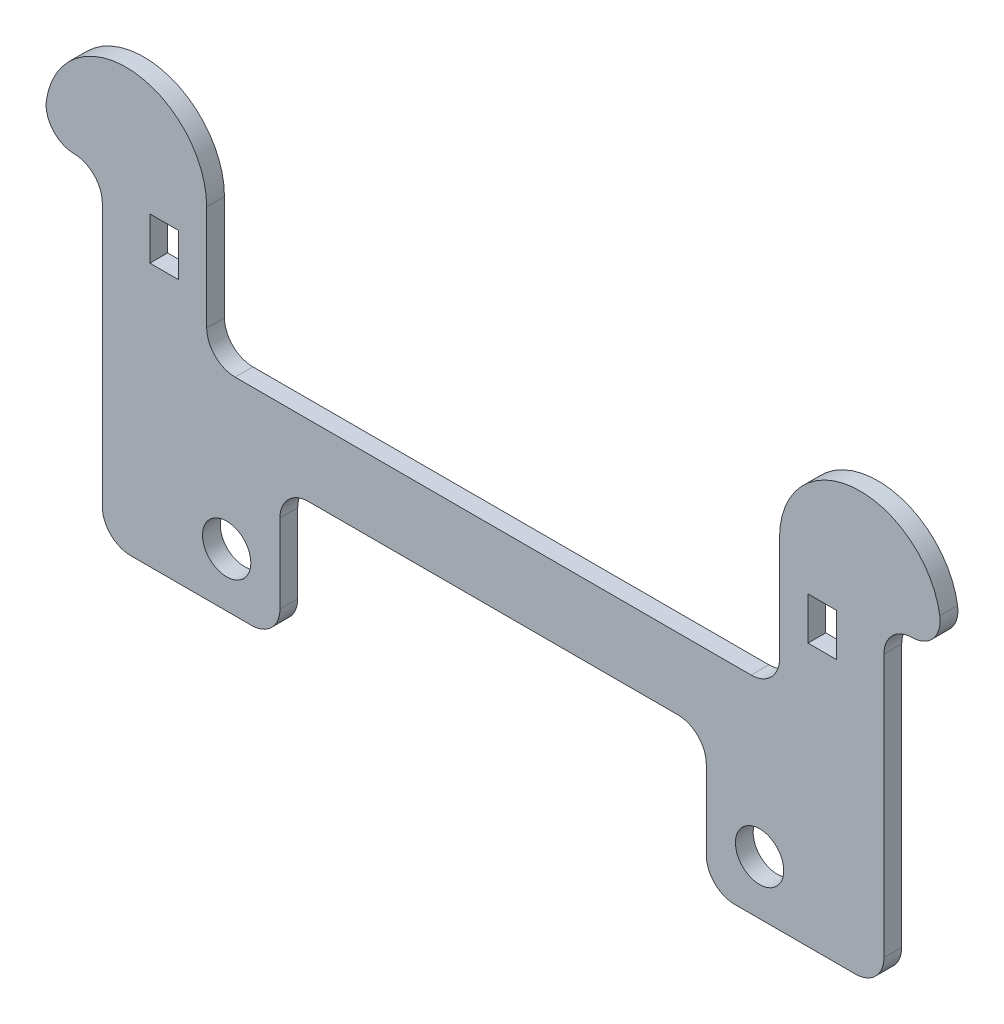
from build123d import *

# Parameters (mm, degrees)
SKETCH1_R           = 2.159
BOSS_EXTRUDE1_DEPTH = 1.5875
SKETCH2_W           = 2.54
SKETCH2_H           = 3.81
CUT_EXTRUDE1_DEPTH  = 1.5875
FILLET1_R           = 2.54
FILLET2_R           = 2.54


with BuildPart() as part:
    # Sketch1 → Boss-Extrude1 (new body)
    with BuildSketch(Plane.XY):
        with BuildLine():
            Line((9.32893445, 30.396375958), (9.32893445, 18.483132928))
            Line((9.32893445, 18.483132928), (60.52106555, 18.483132928))
            Line((60.52106555, 18.483132928), (60.52106555, 30.396375958))
            ThreePointArc((60.52106555, 30.396375958), (67.725532775, 37.600843183), (74.93, 30.396375958))
            Line((74.93, 30.396375958), (74.93, 28.575))
            Line((74.93, 28.575), (69.85, 28.575))
            Line((69.85, 28.575), (69.85, 0))
            Line((69.85, 0), (53.975, 0))
            Line((53.975, 0), (53.975, 12.133132928))
            Line((53.975, 12.133132928), (15.875, 12.133132928))
            Line((15.875, 12.133132928), (15.875, 0))
            Line((15.875, 0), (0, 0))
            Line((0, 0), (0, 28.575))
            Line((0, 28.575), (-5.08, 28.575))
            Line((-5.08, 28.575), (-5.08, 30.396375958))
            ThreePointArc((-5.08, 30.396375958), (2.124467225, 37.600843183), (9.32893445, 30.396375958))
        make_face()
        with Locations((11.1125, 4.805875958)):
            Circle(SKETCH1_R, mode=Mode.SUBTRACT)
        with Locations((58.7375, 4.805875958)):
            Circle(SKETCH1_R, mode=Mode.SUBTRACT)
    extrude(amount=BOSS_EXTRUDE1_DEPTH)

    # Sketch2 → Cut-Extrude1 (cut)
    with BuildSketch(Plane.XY.offset(1.5875)):
        with Locations((5.51893445, 25.4)):
            Rectangle(SKETCH2_W, SKETCH2_H)
        with Locations((64.33106555, 25.4)):
            Rectangle(SKETCH2_W, SKETCH2_H)
    extrude(amount=-CUT_EXTRUDE1_DEPTH, mode=Mode.SUBTRACT)

    # Fillet1
    fillet1_edges = [part.edges().sort_by_distance(p)[0] for p in [
        (60.52106555, 18.483132928, 0.79375),
        (69.85, 28.575, 0.79375),
        (69.85, 0, 0.79375),
        (53.975, 0, 0.79375),
        (53.975, 12.133132928, 0.79375),
        (15.875, 12.133132928, 0.79375),
        (15.875, 0, 0.79375),
        (0, 0, 0.79375),
        (0, 28.575, 0.79375),
        (9.32893445, 18.483132928, 0.79375),
    ]]
    fillet(fillet1_edges, radius=FILLET1_R)

    # Fillet2
    fillet2_edges = [part.edges().sort_by_distance(p)[0] for p in [
        (-5.08, 28.575, 0.79375),
        (74.93, 28.575, 0.79375),
    ]]
    fillet(fillet2_edges, radius=FILLET2_R)


solid = part.part
